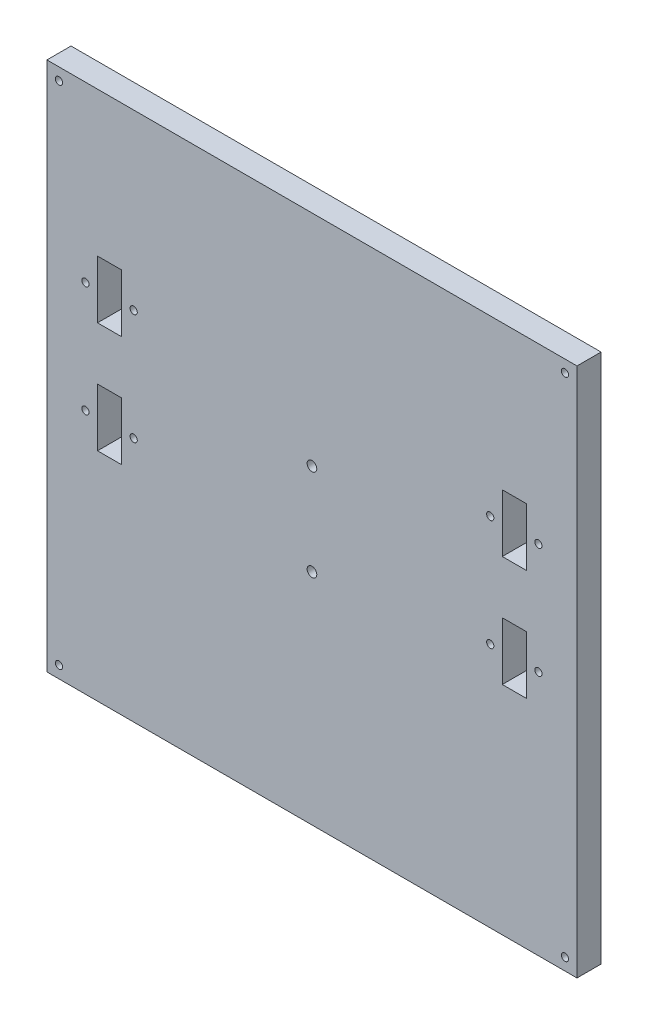
from build123d import *

# Parameters (mm, degrees)
SKETCH2_W           = 220
SKETCH2_H           = 220
BOSS_EXTRUDE2_DEPTH = 10
SKETCH3_R           = 1.5
CUT_EXTRUDE2_DEPTH  = 10
SKETCH4_R           = 1.5
SKETCH4_W           = 10
SKETCH4_H           = 24
CUT_EXTRUDE3_DEPTH  = 10
SKETCH6_R           = 2
CUT_EXTRUDE4_DEPTH  = 10


with BuildPart() as part:
    # Sketch2 → Boss-Extrude2 (new body)
    with BuildSketch(Plane.XY):
        with Locations((222.522330277, 20.812483699)):
            Rectangle(SKETCH2_W, SKETCH2_H)
    extrude(amount=BOSS_EXTRUDE2_DEPTH)

    # Sketch3 → Cut-Extrude2 (cut)
    with BuildSketch(Plane.XY.offset(10)):
        with Locations((117.522330277, 125.812483699)):
            Circle(SKETCH3_R)
        with Locations((117.522330277, -84.187516301)):
            Circle(SKETCH3_R)
        with Locations((327.522330277, -84.187516301)):
            Circle(SKETCH3_R)
        with Locations((327.522330277, 125.812483699)):
            Circle(SKETCH3_R)
    extrude(amount=-CUT_EXTRUDE2_DEPTH, mode=Mode.SUBTRACT)

    # Sketch4 → Cut-Extrude3 (cut)
    with BuildSketch(Plane.XY.offset(10)):
        with Locations((128.522330277, 58.812483699)):
            Circle(SKETCH4_R)
        with Locations((148.522330277, 58.812483699)):
            Circle(SKETCH4_R)
        with Locations((128.522330277, 12.812483699)):
            Circle(SKETCH4_R)
        with Locations((148.522330277, 12.812483699)):
            Circle(SKETCH4_R)
        with Locations((296.522330277, 12.812483699)):
            Circle(SKETCH4_R)
        with Locations((316.522330277, 12.812483699)):
            Circle(SKETCH4_R)
        with Locations((296.522330277, 58.812483699)):
            Circle(SKETCH4_R)
        with Locations((316.522330277, 58.812483699)):
            Circle(SKETCH4_R)
        with Locations((138.522330277, 58.812483699)):
            Rectangle(SKETCH4_W, SKETCH4_H)
        with Locations((138.522330277, 12.812483699)):
            Rectangle(SKETCH4_W, SKETCH4_H)
        with Locations((306.522330277, 58.812483699)):
            Rectangle(SKETCH4_W, SKETCH4_H)
        with Locations((306.522330277, 12.812483699)):
            Rectangle(SKETCH4_W, SKETCH4_H)
    extrude(amount=-CUT_EXTRUDE3_DEPTH, mode=Mode.SUBTRACT)

    # Sketch6 → Cut-Extrude4 (cut)
    with BuildSketch(Plane.XY.offset(10)):
        with Locations((222.522330277, 39.812483699)):
            Circle(SKETCH6_R)
        with Locations((222.522330277, 1.812483699)):
            Circle(SKETCH6_R)
    extrude(amount=-CUT_EXTRUDE4_DEPTH, mode=Mode.SUBTRACT)


solid = part.part
